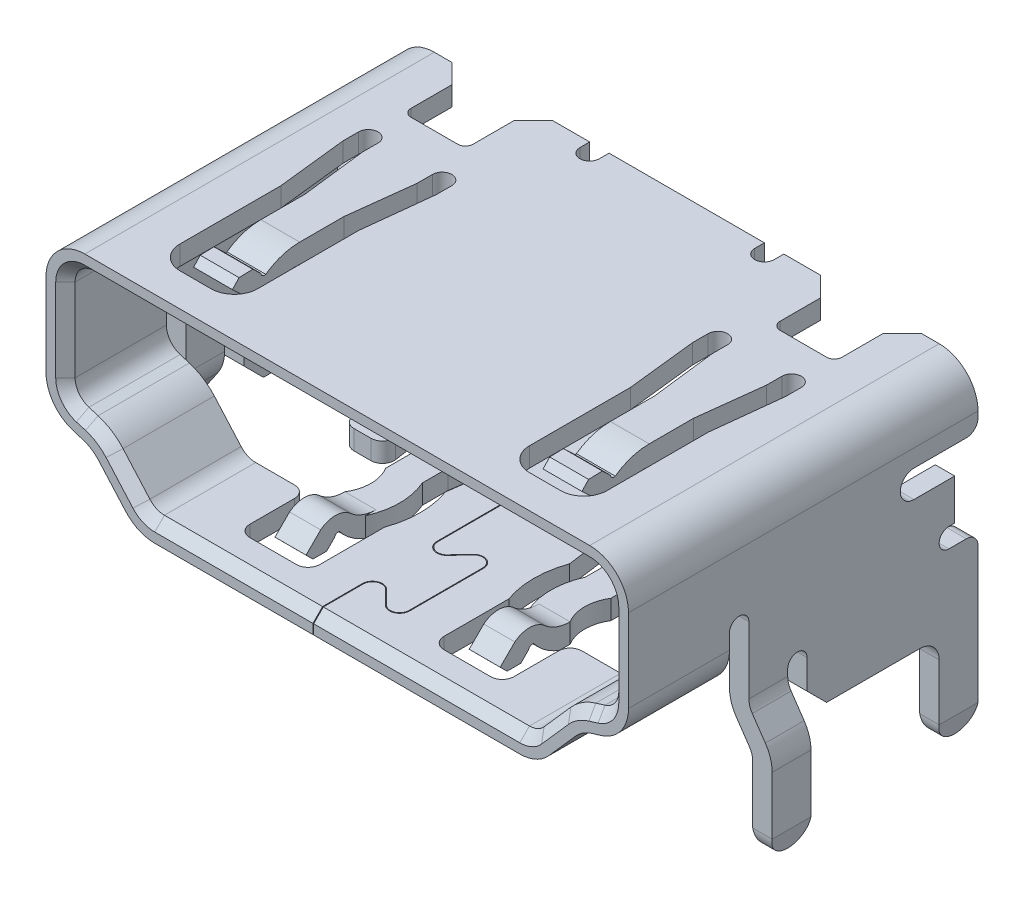
from build123d import *

# Parameters (mm, degrees)
RESSALTO_EXTRUS_O1_DEPTH      = 8.3
RESSALTO_EXTRUS_O1_DEPTH_BACK = 0.7
CHANFRO1_SIZE                 = 0.25
CORTE_EXTRUS_O1_DEPTH         = 3
RESSALTO_EXTRUS_O3_DEPTH      = 0.5
ESBO_O9_W                     = 0.5
ESBO_O9_H                     = 1
FILETE1_R                     = 0.499
FILETE1_OF_ESPELHAR3_R        = 0.499
CORTE_EXTRUS_O2_DEPTH         = 1
CORTE_EXTRUS_O3_DEPTH         = 1
CORTE_EXTRUS_O4_DEPTH         = 1
RESSALTO_EXTRUS_O4_DEPTH      = 0.8
RESSALTO_EXTRUS_O5_DEPTH      = 1
CORTE_EXTRUS_O5_DEPTH         = 11


with BuildPart() as part:
    # Esboço2 → Ressalto-extrusão1 (new body, two sides)
    with BuildSketch(Plane.XY) as ressalto_extrus_o1_sk:
        with BuildLine():
            Line((13.5, 2.775), (26.5, 2.775))
            ThreePointArc((26.5, 2.775), (27.207106781, 2.482106781), (27.5, 1.775))
            Line((27.5, 1.775), (27.5, -0.36))
            ThreePointArc((27.5, -0.36), (27.303276033, -0.95560693), (26.79050477, -1.316873544))
            Line((26.79050477, -1.316873544), (26.553545707, -1.388813811))
            ThreePointArc((26.553545707, -1.388813811), (26.328421757, -1.492872789), (26.140247155, -1.654425825))
            Line((26.140247155, -1.654425825), (25.449725383, -2.436749084))
            ThreePointArc((25.449725383, -2.436749084), (25.111248657, -2.686523199), (24.7, -2.775))
            Line((24.7, -2.775), (15.3, -2.775))
            ThreePointArc((15.3, -2.775), (14.888751343, -2.686523199), (14.550274617, -2.436749084))
            Line((14.550274617, -2.436749084), (13.859752845, -1.654425825))
            ThreePointArc((13.859752845, -1.654425825), (13.671578243, -1.492872789), (13.446454293, -1.388813811))
            Line((13.446454293, -1.388813811), (13.20949523, -1.316873544))
            ThreePointArc((13.20949523, -1.316873544), (12.696723967, -0.95560693), (12.5, -0.36))
            Line((12.5, -0.36), (12.5, 1.775))
            ThreePointArc((12.5, 1.775), (12.792893219, 2.482106781), (13.5, 2.775))
        make_face()
        with BuildLine():
            Line((13.5, 2.275), (26.5, 2.275))
            ThreePointArc((26.5, 2.275), (26.853553391, 2.128553391), (27, 1.775))
            Line((27, 1.775), (27, -0.36))
            ThreePointArc((27, -0.36), (26.901638017, -0.657803465), (26.645252385, -0.838436772))
            Line((26.645252385, -0.838436772), (26.408293321, -0.910377039))
            ThreePointArc((26.408293321, -0.910377039), (26.05810051, -1.072246561), (25.765384464, -1.323551283))
            Line((25.765384464, -1.323551283), (25.074862692, -2.105874542))
            ThreePointArc((25.074862692, -2.105874542), (24.905624329, -2.230761599), (24.7, -2.275))
            Line((24.7, -2.275), (15.3, -2.275))
            ThreePointArc((15.3, -2.275), (15.094375671, -2.230761599), (14.925137308, -2.105874542))
            Line((14.925137308, -2.105874542), (14.234615536, -1.323551283))
            ThreePointArc((14.234615536, -1.323551283), (13.94189949, -1.072246561), (13.591706679, -0.910377039))
            Line((13.591706679, -0.910377039), (13.354747615, -0.838436772))
            ThreePointArc((13.354747615, -0.838436772), (13.098361983, -0.657803465), (13, -0.36))
            Line((13, -0.36), (13, 1.775))
            ThreePointArc((13, 1.775), (13.146446609, 2.128553391), (13.5, 2.275))
        make_face(mode=Mode.SUBTRACT)
    extrude(amount=RESSALTO_EXTRUS_O1_DEPTH)
    extrude(ressalto_extrus_o1_sk.sketch, amount=-RESSALTO_EXTRUS_O1_DEPTH_BACK)

    # Chanfro1
    chanfro1_edges = [part.edges().sort_by_distance(p)[0] for p in [
        (13.94189949, -1.072246561, 8.3),
        (14.579876422, -1.714712912, 8.3),
        (15.094375671, -2.230761599, 8.3),
        (20, -2.275, 8.3),
        (24.905624329, -2.230761599, 8.3),
        (25.420123578, -1.714712912, 8.3),
        (26.05810051, -1.072246561, 8.3),
        (26.526772853, -0.874406905, 8.3),
        (26.901638017, -0.657803465, 8.3),
        (27, 0.7075, 8.3),
        (26.853553391, 2.128553391, 8.3),
        (20, 2.275, 8.3),
        (13.146446609, 2.128553391, 8.3),
        (13, 0.7075, 8.3),
        (13.098361983, -0.657803465, 8.3),
        (13.473227147, -0.874406905, 8.3),
    ]]
    chamfer(chanfro1_edges, length=CHANFRO1_SIZE)

    # Esboço3 → Corte-extrusão1 (cut)
    with BuildSketch(Plane(origin=(27.5, 0, 0), x_dir=(0, 0, -1), z_dir=(1, 0, 0))):
        with BuildLine():
            Line((-5.7, 0.025), (-5.7, -4.040151325))
            Line((-5.7, -4.040151325), (-5.2, -4.040151325))
            Line((-5.2, -4.040151325), (1.122499897, -4.040151325))
            Line((1.122499897, -4.040151325), (1.122499897, -0.225))
            Line((1.122499897, -0.225), (1.122499897, 1.775))
            Line((1.122499897, 1.775), (0.7, 1.775))
            Line((0.7, 1.775), (0.7, 1.625))
            ThreePointArc((0.7, 1.625), (0.612132034, 1.412867966), (0.4, 1.325))
            Line((0.4, 1.325), (-0.95, 1.325))
            ThreePointArc((-0.95, 1.325), (-1.3, 0.975), (-0.95, 0.625))
            Line((-0.95, 0.625), (0.1, 0.625))
            Line((0.1, 0.625), (0.1, -0.225))
            Line((0.1, -0.225), (-5.2, -0.225))
            Line((-5.2, -0.225), (-5.2, 0.025))
            ThreePointArc((-5.2, 0.025), (-5.45, 0.275), (-5.7, 0.025))
        make_face()
    corte_extrus_o1 = extrude(amount=-CORTE_EXTRUS_O1_DEPTH, mode=Mode.SUBTRACT)

    # Espelhar1: Corte-extrusão1 across plane
    add(corte_extrus_o1.mirror(Plane.ZY.offset(-20)), mode=Mode.SUBTRACT)

    # Esboço6 → Ressalto-extrusão3 (add)
    with BuildSketch(Plane(origin=(27.5, 0, 0), x_dir=(0, 0, -1), z_dir=(1, 0, 0))):
        with BuildLine():
            Line((0.1, -0.225), (0.1, -0.425))
            Line((0.1, -0.425), (-0.05, -0.425))
            ThreePointArc((-0.05, -0.425), (-0.3, -0.675), (-0.05, -0.925))
            Line((-0.05, -0.925), (0.4, -0.925))
            ThreePointArc((0.4, -0.925), (0.612132034, -1.012867966), (0.7, -1.225))
            Line((0.7, -1.225), (0.7, -4.725))
            ThreePointArc((0.7, -4.725), (0.2, -5.225), (-0.3, -4.725))
            Line((-0.3, -4.725), (-0.3, -3.275))
            ThreePointArc((-0.3, -3.275), (-0.446446609, -2.921446609), (-0.8, -2.775))
            Line((-0.8, -2.775), (-3.2, -2.775))
            Line((-3.2, -2.775), (-3.7, -2.275))
            Line((-3.7, -2.275), (-3.7, -1.525))
            ThreePointArc((-3.7, -1.525), (-3.95, -1.275), (-4.2, -1.525))
            Line((-4.2, -1.525), (-4.2, -1.695))
            Line((-4.2, -1.695), (-5.2, -1.695))
            Line((-5.2, -1.695), (-5.2, -1.05080475))
            Line((-5.2, -1.05080475), (-5.2, -0.225))
            Line((-5.2, -0.225), (0.1, -0.225))
        make_face()
    ressalto_extrus_o3 = extrude(amount=-RESSALTO_EXTRUS_O3_DEPTH)

    # Espelhar2: Ressalto-extrusão3 across plane
    add(ressalto_extrus_o3.mirror(Plane.ZY.offset(-20)))

    # Varredura1: sweep along a path in Esboço8
    with BuildLine(Plane.XY.offset(5.2)) as varredura1_path:
        Line((27.849, -5.025), (27.849, -3.035))
        ThreePointArc((27.849, -3.035), (27.815578161, -2.813089059), (27.718, -2.611))
        Line((27.718, -2.611), (27.381, -2.119))
        ThreePointArc((27.381, -2.119), (27.283421839, -1.916910941), (27.25, -1.695))
    # Esboço9 → Varredura1 (sweep)
    with BuildSketch(Plane.XZ.offset(1.695)):
        with Locations((27.25, 4.7)):
            Rectangle(ESBO_O9_W, ESBO_O9_H)
    varredura1 = sweep(path=varredura1_path.line, transition=Transition.RIGHT)

    # Filete1
    filete1_edges = [part.edges().sort_by_distance(p)[0] for p in [
        (27.849, -5.025, 4.2),
        (27.849, -5.025, 5.2),
    ]]
    fillet(filete1_edges, radius=FILETE1_R)

    # Espelhar3: Varredura1 across plane
    add(varredura1.mirror(Plane.ZY.offset(-20)))

    # Filete1 of Espelhar3
    filete1_of_espelhar3_edges = [part.edges().sort_by_distance(p)[0] for p in [
        (12.151, -5.025, 4.2),
        (12.151, -5.025, 5.2),
    ]]
    fillet(filete1_of_espelhar3_edges, radius=FILETE1_OF_ESPELHAR3_R)

    # Esboço10 → Corte-extrusão2 (cut)
    with BuildSketch(Plane(origin=(0, 2.775, 0), x_dir=(1, 0, 0), z_dir=(0, 1, 0))):
        with BuildLine():
            Line((26.05, 0.7), (25.55, 0.2))
            Line((25.55, 0.2), (25.55, -0.85))
            ThreePointArc((25.55, -0.85), (25.491421356, -0.991421356), (25.35, -1.05))
            Line((25.35, -1.05), (24.15, -1.05))
            ThreePointArc((24.15, -1.05), (24.008578644, -0.991421356), (23.95, -0.85))
            Line((23.95, -0.85), (23.95, 0.2))
            Line((23.95, 0.2), (23.45, 0.7))
            Line((23.45, 0.7), (22.5, 0.7))
            Line((22.5, 0.7), (22.5, 0.45))
            ThreePointArc((22.5, 0.45), (22.25, 0.2), (22, 0.45))
            Line((22, 0.45), (22, 1.825806464))
            Line((22, 1.825806464), (26.05, 1.825806464))
            Line((26.05, 1.825806464), (26.05, 0.7))
        make_face()
        with BuildLine():
            Line((24.1, -7.45), (24.9, -7.45))
            ThreePointArc((24.9, -7.45), (25.324264069, -7.274264069), (25.5, -6.85))
            Line((25.5, -6.85), (25.5, -4.25))
            Line((25.5, -4.25), (25.7, -2.45))
            Line((25.7, -2.45), (25.7, -2.05))
            ThreePointArc((25.7, -2.05), (25.45, -1.8), (25.2, -2.05))
            Line((25.2, -2.05), (25.2, -2.45))
            Line((25.2, -2.45), (25, -4.13))
            Line((25, -4.13), (25, -4.25))
            Line((25, -4.25), (25, -5.2673))
            Line((25, -5.2673), (24, -5.2673))
            Line((24, -5.2673), (24, -4.25))
            Line((24, -4.25), (24, -4.13))
            Line((24, -4.13), (23.8, -2.45))
            Line((23.8, -2.45), (23.8, -2.05))
            ThreePointArc((23.8, -2.05), (23.55, -1.8), (23.3, -2.05))
            Line((23.3, -2.05), (23.3, -2.45))
            Line((23.3, -2.45), (23.5, -4.25))
            Line((23.5, -4.25), (23.5, -6.85))
            ThreePointArc((23.5, -6.85), (23.675735931, -7.274264069), (24.1, -7.45))
        make_face()
    corte_extrus_o2 = extrude(amount=-CORTE_EXTRUS_O2_DEPTH, mode=Mode.SUBTRACT)

    # Espelhar4: Corte-extrusão2 across plane
    add(corte_extrus_o2.mirror(Plane.ZY.offset(-20)), mode=Mode.SUBTRACT)

    # Esboço11 → Corte-extrusão3 (cut)
    with BuildSketch(Plane.XZ.offset(2.775)):
        with BuildLine():
            Line((15.5, 5.7), (16.3, 5.7))
            ThreePointArc((16.3, 5.7), (16.512132034, 5.787867966), (16.6, 6))
            Line((16.6, 6), (16.6, 7.15))
            ThreePointArc((16.6, 7.15), (16.687867966, 7.362132034), (16.9, 7.45))
            Line((16.9, 7.45), (18.1, 7.45))
            ThreePointArc((18.1, 7.45), (18.312132034, 7.362132034), (18.4, 7.15))
            Line((18.4, 7.15), (18.4, 5.482))
            ThreePointArc((18.4, 5.482), (18.537021498, 4.7), (18.4, 3.918))
            Line((18.4, 3.918), (18.6, 2.45))
            Line((18.6, 2.45), (18.6, 1.95))
            ThreePointArc((18.6, 1.95), (18.35, 1.7), (18.1, 1.95))
            Line((18.1, 1.95), (17.9, 3.35))
            Line((17.9, 3.35), (17.9, 4.01))
            ThreePointArc((17.9, 4.01), (18.055740215, 4.7424), (17.9, 5.4748))
            Line((17.9, 5.4748), (17.1, 5.4748))
            Line((17.1, 5.4748), (17.1, 5.2048))
            ThreePointArc((17.1, 5.2048), (17.249484511, 4.67885), (17.1, 4.1529))
            Line((17.1, 4.1529), (17.1, 3.3272))
            Line((17.1, 3.3272), (16.9105, 1.9257))
            ThreePointArc((16.9105, 1.9257), (16.6605, 1.6757), (16.4105, 1.9257))
            Line((16.4105, 1.9257), (16.4105, 2.4257))
            Line((16.4105, 2.4257), (16.5376, 3.3341))
            ThreePointArc((16.5376, 3.3341), (16.466861376, 3.572574941), (16.2405, 3.6757))
            Line((16.2405, 3.6757), (15.8106, 3.6757))
            ThreePointArc((15.8106, 3.6757), (15.598467966, 3.587832034), (15.5106, 3.3757))
            Line((15.5106, 3.3757), (15.5106, 1.3757))
            Line((15.5106, 1.3757), (16.0106, 0.8757))
            Line((16.0106, 0.8757), (17.7106, 0.8757))
            ThreePointArc((17.7106, 0.8757), (17.922732034, 0.787832034), (18.0106, 0.5757))
            Line((18.0106, 0.5757), (18.0106, 0.3757))
            ThreePointArc((18.0106, 0.3757), (18.098467966, 0.163567966), (18.3106, 0.0757))
            Line((18.3106, 0.0757), (20, 0.0757))
            Line((20, 0.0757), (20, -1.100530022))
            Line((20, -1.100530022), (14.919265786, -1.100530022))
            Line((14.919265786, -1.100530022), (14.919265786, 5.2048))
            Line((14.919265786, 5.2048), (15.5, 5.7))
        make_face()
    corte_extrus_o3 = extrude(amount=-CORTE_EXTRUS_O3_DEPTH, mode=Mode.SUBTRACT)

    # Espelhar5: Corte-extrusão3 across plane
    add(corte_extrus_o3.mirror(Plane.ZY.offset(-20)), mode=Mode.SUBTRACT)

    # Esboço12 → Corte-extrusão4 (cut)
    with BuildSketch(Plane.XZ.offset(2.775)):
        with BuildLine():
            Line((19.4106, -0.117707226), (19.4106, 1.3257))
            ThreePointArc((19.4106, 1.3257), (19.55986004, 1.547848771), (19.82196, 1.493698543))
            Line((19.82196, 1.493698543), (20.164857851, 1.143800735))
            ThreePointArc((20.164857851, 1.143800735), (20.448800933, 1.085135514), (20.6105, 1.325798543))
            Line((20.6105, 1.325798543), (20.6105, 3.2258))
            ThreePointArc((20.6105, 3.2258), (20.448803028, 3.46646363), (20.16486, 3.407801457))
            Line((20.16486, 3.407801457), (19.821957851, 3.057899265))
            ThreePointArc((19.821957851, 3.057899265), (19.559857945, 3.003752084), (19.4106, 3.225901457))
            Line((19.4106, 3.225901457), (19.4106, 5.1259))
            ThreePointArc((19.4106, 5.1259), (19.559797725, 5.348023312), (19.821865712, 5.293994643))
            Line((19.821865712, 5.293994643), (20.146784929, 4.944096638))
            ThreePointArc((20.146784929, 4.944096638), (20.430759842, 4.885310137), (20.59252107, 5.125998543))
            Line((20.59252107, 5.125998543), (20.59252107, 7.026))
            ThreePointArc((20.59252107, 7.026), (20.430824098, 7.26666363), (20.14688107, 7.208001457))
            Line((20.14688107, 7.208001457), (19.803978921, 6.858099265))
            ThreePointArc((19.803978921, 6.858099265), (19.541879015, 6.803952084), (19.39262107, 7.026101457))
            Line((19.39262107, 7.026101457), (19.39262107, 9.06575703))
            ThreePointArc((19.39262107, 9.06575703), (19.38262107, 9.07575703), (19.37262107, 9.06575703))
            Line((19.37262107, 9.06575703), (19.37262107, 7.026098543))
            ThreePointArc((19.37262107, 7.026098543), (19.534320137, 6.785435514), (19.818263219, 6.844100735))
            Line((19.818263219, 6.844100735), (20.16116107, 7.193998543))
            ThreePointArc((20.16116107, 7.193998543), (20.42326103, 7.248148771), (20.57252107, 7.026))
            Line((20.57252107, 7.026), (20.57252107, 5.126001457))
            ThreePointArc((20.57252107, 5.126001457), (20.423324019, 4.903876964), (20.161255358, 4.957905357))
            Line((20.161255358, 4.957905357), (19.836336141, 5.307803362))
            ThreePointArc((19.836336141, 5.307803362), (19.552360554, 5.366589588), (19.3906, 5.1259))
            Line((19.3906, 5.1259), (19.3906, 3.225898543))
            ThreePointArc((19.3906, 3.225898543), (19.552299067, 2.985235514), (19.836242149, 3.043900735))
            Line((19.836242149, 3.043900735), (20.17914, 3.393798543))
            ThreePointArc((20.17914, 3.393798543), (20.44123996, 3.447948771), (20.5905, 3.2258))
            Line((20.5905, 3.2258), (20.5905, 1.325801457))
            ThreePointArc((20.5905, 1.325801457), (20.441242055, 1.103652084), (20.179142149, 1.157799265))
            Line((20.179142149, 1.157799265), (19.83624, 1.507701457))
            ThreePointArc((19.83624, 1.507701457), (19.552296972, 1.56636363), (19.3906, 1.3257))
            Line((19.3906, 1.3257), (19.3906, -0.117707226))
            ThreePointArc((19.3906, -0.117707226), (19.4006, -0.127707226), (19.4106, -0.117707226))
        make_face()
    extrude(amount=-CORTE_EXTRUS_O4_DEPTH, mode=Mode.SUBTRACT)

    # Esboço14 → Ressalto-extrusão4 (add)
    with BuildSketch(Plane(origin=(22.9, 0, 0), x_dir=(0, 0, -1), z_dir=(1, 0, 0))):
        with BuildLine():
            Line((-5.2048, -2.275), (-5.2048, -2.775))
            Line((-5.2048, -2.775), (-5.4748, -2.775))
            ThreePointArc((-5.4748, -2.775), (-5.841679986, -2.580565027), (-6.1412, -2.293))
            ThreePointArc((-6.1412, -2.293), (-6.224464799, -2.298955914), (-6.2742, -2.366))
            Line((-6.2742, -2.366), (-6.4736, -2.5647))
            Line((-6.4736, -2.5647), (-6.8272, -2.5647))
            Line((-6.8272, -2.5647), (-7.0036, -2.3876))
            Line((-7.0036, -2.3876), (-6.627, -2.0125))
            ThreePointArc((-6.627, -2.0125), (-6.219665294, -1.882151027), (-5.829, -2.0562))
            ThreePointArc((-5.829, -2.0562), (-5.535514016, -2.218702692), (-5.2048, -2.275))
        make_face()
    ressalto_extrus_o4 = extrude(amount=-RESSALTO_EXTRUS_O4_DEPTH)

    # Esboço15 → Ressalto-extrusão5 (add)
    with BuildSketch(Plane(origin=(25, 0, 0), x_dir=(0, 0, -1), z_dir=(1, 0, 0))):
        with BuildLine():
            Line((-5.2673, 2.275), (-5.2673, 2.775))
            ThreePointArc((-5.2673, 2.775), (-5.726561738, 2.702927261), (-6.1417, 2.4937))
            ThreePointArc((-6.1417, 2.4937), (-6.224873413, 2.506754104), (-6.2686, 2.5787))
            Line((-6.2686, 2.5787), (-6.475, 2.7735))
            Line((-6.475, 2.7735), (-6.8284, 2.7633))
            Line((-6.8284, 2.7633), (-7, 2.5815))
            Line((-7, 2.5815), (-6.6118, 2.2151))
            ThreePointArc((-6.6118, 2.2151), (-6.240173676, 2.052824535), (-5.8502, 2.164))
            ThreePointArc((-5.8502, 2.164), (-5.56717269, 2.263730503), (-5.2673, 2.275))
        make_face()
    ressalto_extrus_o5 = extrude(amount=-RESSALTO_EXTRUS_O5_DEPTH)

    # Espelhar6: Ressalto-extrusão4, Ressalto-extrusão5 across plane
    add(ressalto_extrus_o4.mirror(Plane.ZY.offset(-20)))
    add(ressalto_extrus_o5.mirror(Plane.ZY.offset(-20)))

    # Esboço16 → Corte-extrusão5 (cut)
    with BuildSketch(Plane.XY.offset(5.2)):
        Polygon((28.099, -4.526), (27.999, -5.025), (27.699, -5.025), (27.599, -4.526), (27.555323028, -4.526), (27.5, -4.725), (27.4, -5.225), (27.1, -5.225), (27, -4.725), (26.815237852, -4.725), (26.815237852, -5.379816457), (28.2402866, -5.379816457), (28.2402866, -4.526), align=None)
    corte_extrus_o5 = extrude(amount=-CORTE_EXTRUS_O5_DEPTH, mode=Mode.SUBTRACT)

    # Espelhar7: Corte-extrusão5 across plane
    add(corte_extrus_o5.mirror(Plane.ZY.offset(-20)), mode=Mode.SUBTRACT)


solid = part.part
